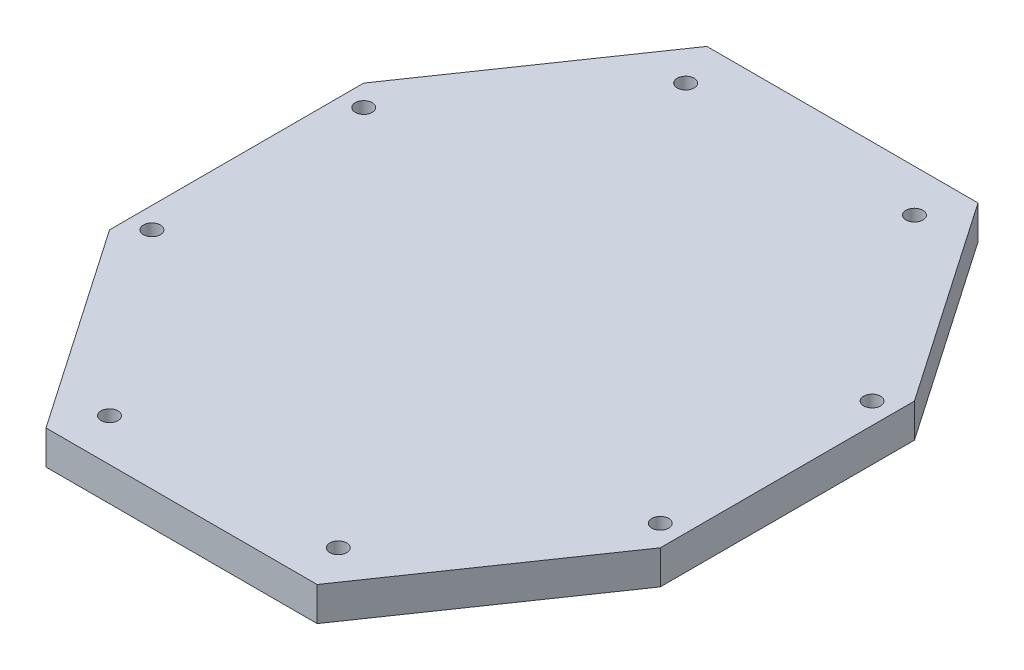
from build123d import *

# Parameters (mm, degrees)
SKETCH_1_R      = 2
EXTRUDE_1_DEPTH = 8


with BuildPart() as part:
    # 草图1 → 凸台-拉伸1 (new body)
    with BuildSketch(Plane(origin=(0, 0, 0), x_dir=(1, 0, 0), z_dir=(0, 1, 0))):
        Polygon((32, 53), (65, 5), (65, -55), (32, -103), (-32, -103), (-65, -55), (-65, 5), (-32, 53), align=None)
        with Locations((27, -93)):
            Circle(SKETCH_1_R, mode=Mode.SUBTRACT)
        with Locations((27, 43)):
            Circle(SKETCH_1_R, mode=Mode.SUBTRACT)
        with Locations((60, 0)):
            Circle(SKETCH_1_R, mode=Mode.SUBTRACT)
        with Locations((60, -50)):
            Circle(SKETCH_1_R, mode=Mode.SUBTRACT)
        with Locations((-27, -93)):
            Circle(SKETCH_1_R, mode=Mode.SUBTRACT)
        with Locations((-60, -50)):
            Circle(SKETCH_1_R, mode=Mode.SUBTRACT)
        with Locations((-60, 0)):
            Circle(SKETCH_1_R, mode=Mode.SUBTRACT)
        with Locations((-27, 43)):
            Circle(SKETCH_1_R, mode=Mode.SUBTRACT)
    extrude(amount=EXTRUDE_1_DEPTH)


solid = part.part
